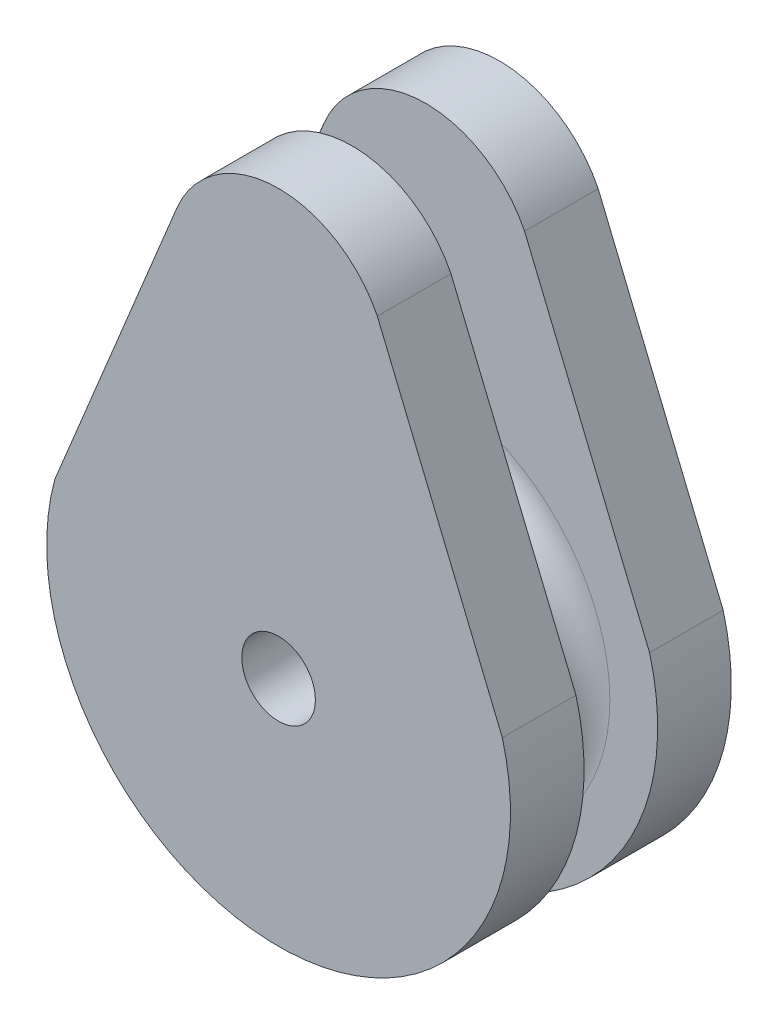
from build123d import *

# Parameters (mm, degrees)
EXTRUDE_1_DEPTH     = 4
SKETCH_2_R          = 8
EXTRUDE_2_DEPTH     = 4
SKETCH_12_W         = 4
SKETCH_12_H         = 2
SKETCH_13_R         = 2
SKETCH_14_R         = 2
CUT_EXTRUDE_1_DEPTH = 1
SKETCH_15_R         = 2
CUT_EXTRUDE_2_DEPTH = 13


with BuildPart() as part:
    # 草图1 → 凸台-拉伸1 (new body)
    with BuildSketch(Plane.XY):
        with BuildLine():
            ThreePointArc((-12.158788541, 3.305126504), (0, -12.6), (12.158788541, 3.305126504))
            Line((12.158788541, 3.305126504), (5.366883622, 19.743511481))
            ThreePointArc((5.366883622, 19.743511481), (-0.204686635, 23.072677305), (-5.535757021, 19.370592925))
            Line((-5.535757021, 19.370592925), (-12.158788541, 3.305126504))
        make_face()
    extrude_1 = extrude(amount=EXTRUDE_1_DEPTH)

    # 草图2 → 凸台-拉伸2 (add)
    with BuildSketch(Plane.XY.offset(4)):
        Circle(SKETCH_2_R)
    extrude(amount=EXTRUDE_2_DEPTH)

    # 镜向1: 凸台-拉伸1 across plane
    add(extrude_1.mirror(Plane.XY.offset(6)))

    # 草图12 → 旋转3 (revolve)
    with BuildSketch(Plane(origin=(0, 0, 0), x_dir=(0, 0, -1), z_dir=(1, 0, 0))):
        with Locations((-6, 9)):
            Rectangle(SKETCH_12_W, SKETCH_12_H)
    revolve(axis=Axis((0, 0, -2.657619659), (0, 0, 1)))

    # 草图13 → 切除-旋转1 (revolve, cut)
    with BuildSketch(Plane(origin=(0, 0, 0), x_dir=(0, 0, -1), z_dir=(1, 0, 0))):
        with Locations((-6, 10)):
            Circle(SKETCH_13_R)
    revolve(axis=Axis((0, 0, -2.657619659), (0, 0, 1)), mode=Mode.SUBTRACT)

    # 草图14 → 切除-拉伸1 (cut)
    with BuildSketch(Plane(origin=(0, 0, 0), x_dir=(-1, 0, 0), z_dir=(0, 0, -1))):
        Circle(SKETCH_14_R)
    extrude(amount=-CUT_EXTRUDE_1_DEPTH, mode=Mode.SUBTRACT)

    # 草图15 → 切除-拉伸2 (cut, through all)
    with BuildSketch(Plane.XY.offset(12)):
        Circle(SKETCH_15_R)
    extrude(amount=-CUT_EXTRUDE_2_DEPTH, mode=Mode.SUBTRACT)


solid = part.part
